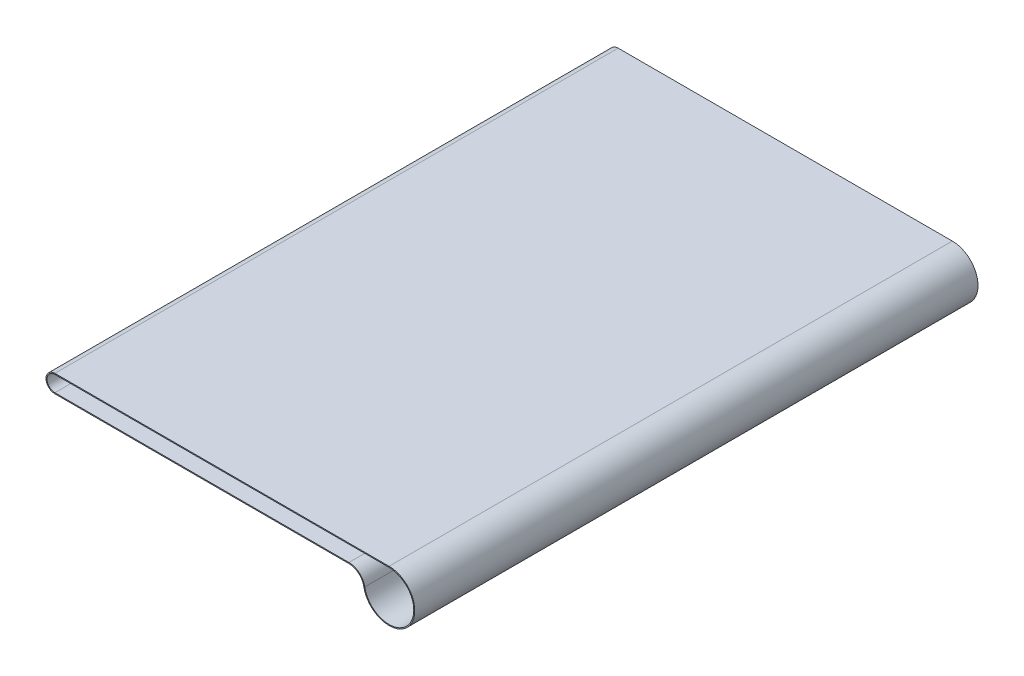
from build123d import *

# Parameters (mm, degrees)
EXTRUDE_1_DEPTH = 570


with BuildPart() as part:
    # 草图1 → 凸台-拉伸1 (new body)
    with BuildSketch(Plane.XY):
        with BuildLine():
            Line((-12.404964531, 1), (325.76800896, 1))
            ThreePointArc((325.76800896, 1), (345.710427238, -41.682324575), (300.176786305, -29.59231129))
            ThreePointArc((300.176786305, -29.59231129), (294.936443949, -20.563156945), (285.123660003, -17))
            Line((285.123660003, -17), (-12.404964531, -17))
            ThreePointArc((-12.404964531, -17), (-21.404964531, -8), (-12.404964531, 1))
        make_face()
        with BuildLine():
            Line((-12.404964531, 0), (325.76800896, 0))
            ThreePointArc((325.76800896, 0), (344.943411151, -41.040696707), (301.161064099, -29.415683933))
            ThreePointArc((301.161064099, -29.415683933), (295.578071817, -19.796140858), (285.123660003, -16))
            Line((285.123660003, -16), (-12.404964531, -16))
            ThreePointArc((-12.404964531, -16), (-20.404964531, -8), (-12.404964531, 0))
        make_face(mode=Mode.SUBTRACT)
    extrude(amount=EXTRUDE_1_DEPTH)


solid = part.part
